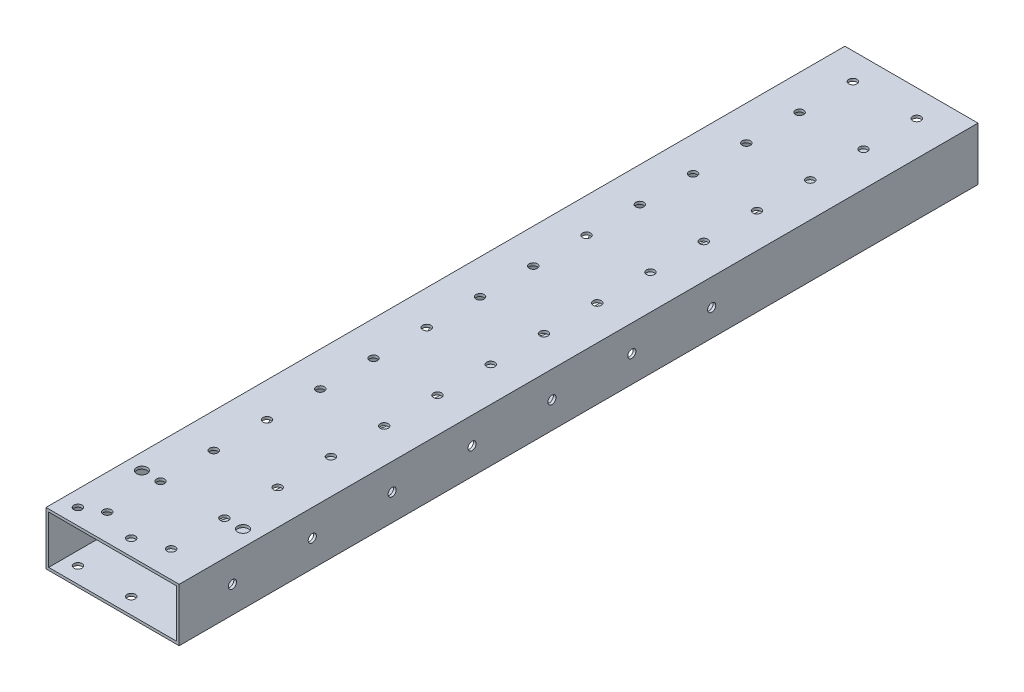
from build123d import *

# Parameters (mm, degrees)
SKETCH_1_W             = 50
SKETCH_1_H             = 20
SKETCH_1_W_2           = 48
SKETCH_1_H_2           = 18
EXTRUDE_1_DEPTH        = 150
SKETCH_2_R             = 1.525
CUT_EXTRUDE_1_DEPTH    = 10
PATTERN_LINEAR_1_COUNT = 15
PATTERN_LINEAR_1_PITCH = 20
SKETCH_3_R             = 1.525
CUT_EXTRUDE_2_DEPTH    = 100
SKETCH_4_R             = 1.525
CUT_EXTRUDE_3_DEPTH    = 100
SKETCH_5_R             = 2.025
CUT_EXTRUDE_4_DEPTH    = 39
SKETCH_7_R             = 5.5
CUT_EXTRUDE_6_DEPTH    = 10
CUT_EXTRUDE_7_DEPTH    = 10
PATTERN_LINEAR_2_COUNT = 4
PATTERN_LINEAR_2_PITCH = 60
SKETCH_9_R             = 5.5
CUT_EXTRUDE_8_DEPTH    = 10
PATTERN_LINEAR_3_COUNT = 6
PATTERN_LINEAR_3_PITCH = 30
SKETCH_10_R            = 2.025
CUT_EXTRUDE_9_DEPTH    = 10
SKETCH_11_R            = 2.025
CUT_EXTRUDE_10_DEPTH   = 8


with BuildPart() as part:
    # 草图1 → 凸台-拉伸1 (new body, symmetric)
    with BuildSketch(Plane.XY):
        Rectangle(SKETCH_1_W, SKETCH_1_H)
        Rectangle(SKETCH_1_W_2, SKETCH_1_H_2, mode=Mode.SUBTRACT)
    extrude(amount=EXTRUDE_1_DEPTH, both=True)

    # 草图2 → 切除-拉伸1 (cut)
    with BuildSketch(Plane(origin=(0, 10, 0), x_dir=(1, 0, 0), z_dir=(0, 1, 0))):
        with Locations((-12, -140)):
            Circle(SKETCH_2_R)
        with Locations((12, -140)):
            Circle(SKETCH_2_R)
    cut_extrude_1 = extrude(amount=-CUT_EXTRUDE_1_DEPTH, mode=Mode.SUBTRACT)

    # 阵列(线性)1: 切除-拉伸1 ×15
    with Locations(*[(0, 0, -i * PATTERN_LINEAR_1_PITCH) for i in range(1, PATTERN_LINEAR_1_COUNT)]):
        add(cut_extrude_1, mode=Mode.SUBTRACT)

    # 草图3 → 切除-拉伸2 (cut)
    with BuildSketch(Plane(origin=(25, 0, 0), x_dir=(0, 0, -1), z_dir=(1, 0, 0))):
        with Locations((50, 0)):
            Circle(SKETCH_3_R)
        with Locations((20, 0)):
            Circle(SKETCH_3_R)
        with Locations((-10, 0)):
            Circle(SKETCH_3_R)
        with Locations((-40, 0)):
            Circle(SKETCH_3_R)
        with Locations((-70, 0)):
            Circle(SKETCH_3_R)
        with Locations((-100, 0)):
            Circle(SKETCH_3_R)
        with Locations((-130, 0)):
            Circle(SKETCH_3_R)
    extrude(amount=-CUT_EXTRUDE_2_DEPTH, mode=Mode.SUBTRACT)

    # 草图4 → 切除-拉伸3 (cut)
    with BuildSketch(Plane.XZ.offset(10)):
        with Locations((-19, 144)):
            Circle(SKETCH_4_R)
        with Locations((1, 144)):
            Circle(SKETCH_4_R)
    extrude(amount=-CUT_EXTRUDE_3_DEPTH, mode=Mode.SUBTRACT)

    # 草图5 → 切除-拉伸4 (cut)
    with BuildSketch(Plane.XZ.offset(10)):
        with Locations((19, 120)):
            Circle(SKETCH_5_R)
        with Locations((-19, 120)):
            Circle(SKETCH_5_R)
    extrude(amount=-CUT_EXTRUDE_4_DEPTH, mode=Mode.SUBTRACT)

    # 草图7 → 切除-拉伸6 (cut)
    with BuildSketch(Plane(origin=(0, -9, 0), x_dir=(1, 0, 0), z_dir=(0, 1, 0))):
        with Locations((-12, -100)):
            Circle(SKETCH_7_R)
        with Locations((12, -100)):
            Circle(SKETCH_7_R)
    extrude(amount=-CUT_EXTRUDE_6_DEPTH, mode=Mode.SUBTRACT)

    # 草图6 → 切除-拉伸7 (cut)
    with BuildSketch(Plane(origin=(0, -9, 0), x_dir=(1, 0, 0), z_dir=(0, 1, 0))):
        with BuildLine():
            Line((-6.5, 100), (-6.5, 80))
            ThreePointArc((-6.5, 80), (-12, 74.5), (-17.5, 80))
            Line((-17.5, 80), (-17.5, 100))
            ThreePointArc((-17.5, 100), (-12, 105.5), (-6.5, 100))
        make_face()
        with BuildLine():
            Line((6.5, 100), (6.5, 80))
            ThreePointArc((6.5, 80), (12, 74.5), (17.5, 80))
            Line((17.5, 80), (17.5, 100))
            ThreePointArc((17.5, 100), (12, 105.5), (6.5, 100))
        make_face()
    cut_extrude_7 = extrude(amount=-CUT_EXTRUDE_7_DEPTH, mode=Mode.SUBTRACT)

    # 阵列(线性)2: 切除-拉伸7 ×4
    with Locations(*[(0, 0, i * PATTERN_LINEAR_2_PITCH) for i in range(1, PATTERN_LINEAR_2_COUNT)]):
        add(cut_extrude_7, mode=Mode.SUBTRACT)

    # 草图9 → 切除-拉伸8 (cut)
    with BuildSketch(Plane.ZY.offset(25)):
        with Locations((-50, 0)):
            Circle(SKETCH_9_R)
    cut_extrude_8 = extrude(amount=-CUT_EXTRUDE_8_DEPTH, mode=Mode.SUBTRACT)

    # 阵列(线性)3: 切除-拉伸8 ×6
    with Locations(*[(0, 0, i * PATTERN_LINEAR_3_PITCH) for i in range(1, PATTERN_LINEAR_3_COUNT)]):
        add(cut_extrude_8, mode=Mode.SUBTRACT)

    # 草图10 → 切除-拉伸9 (cut)
    with BuildSketch(Plane.XZ.offset(10)):
        with Locations((19, -140)):
            Circle(SKETCH_10_R)
        with Locations((-19, -140)):
            Circle(SKETCH_10_R)
    extrude(amount=-CUT_EXTRUDE_9_DEPTH, mode=Mode.SUBTRACT)

    # 草图11 → 切除-拉伸10 (cut)
    with BuildSketch(Plane.XZ.offset(10)):
        with Locations((-19, -122)):
            Circle(SKETCH_11_R)
        with Locations((19, -122)):
            Circle(SKETCH_11_R)
    extrude(amount=-CUT_EXTRUDE_10_DEPTH, mode=Mode.SUBTRACT)


solid = part.part
